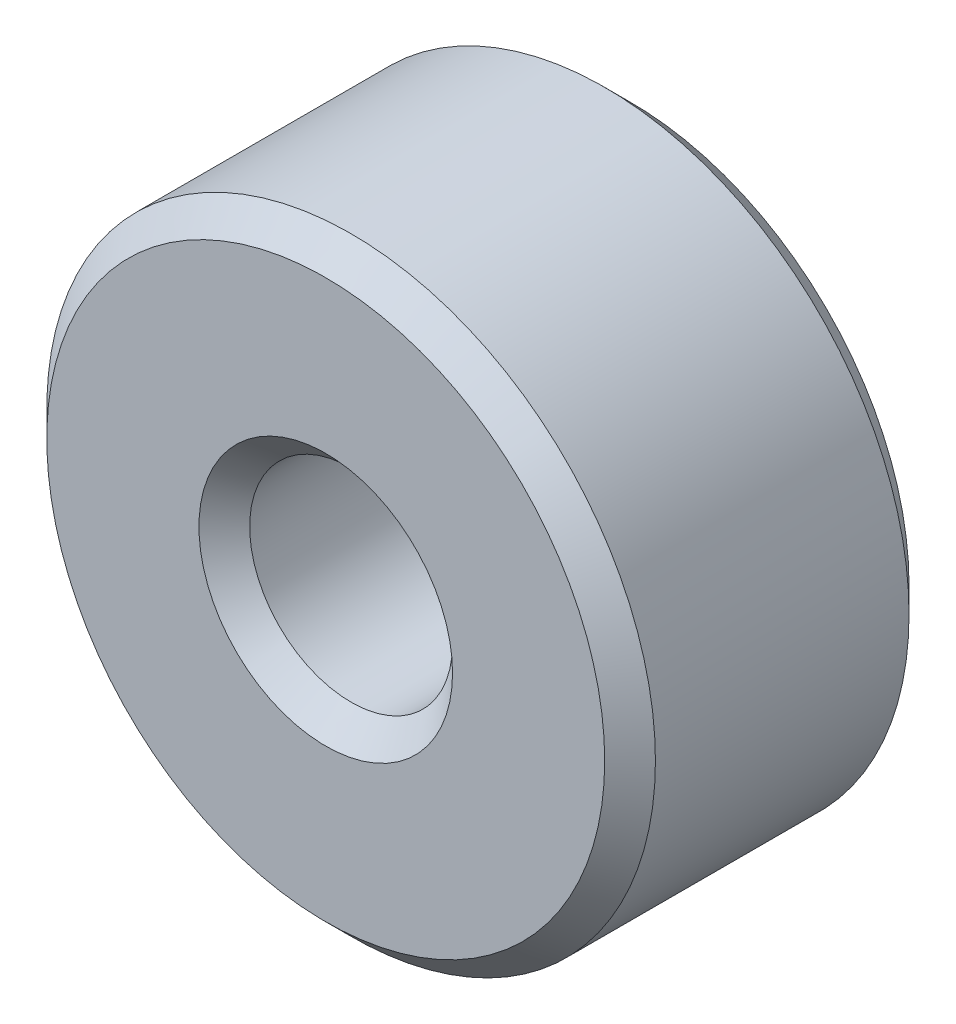
from build123d import *

# Parameters (mm, degrees)
SKETCH1_R           = 3
SKETCH1_R_2         = 1
EXTRUDE_THIN1_DEPTH = 3
CHAMFER1_SIZE       = 0.25


with BuildPart() as part:
    # Sketch1 → Extrude-Thin1 (new body)
    with BuildSketch(Plane.XY):
        Circle(SKETCH1_R)
        Circle(SKETCH1_R_2, mode=Mode.SUBTRACT)
    extrude(amount=EXTRUDE_THIN1_DEPTH)

    # Chamfer1
    chamfer1_edges = [part.edges().sort_by_distance(p)[0] for p in [
        (-3, 0, 0),
        (-1, 0, 0),
        (-3, 0, 3),
        (-1, 0, 3),
    ]]
    chamfer(chamfer1_edges, length=CHAMFER1_SIZE)


solid = part.part
